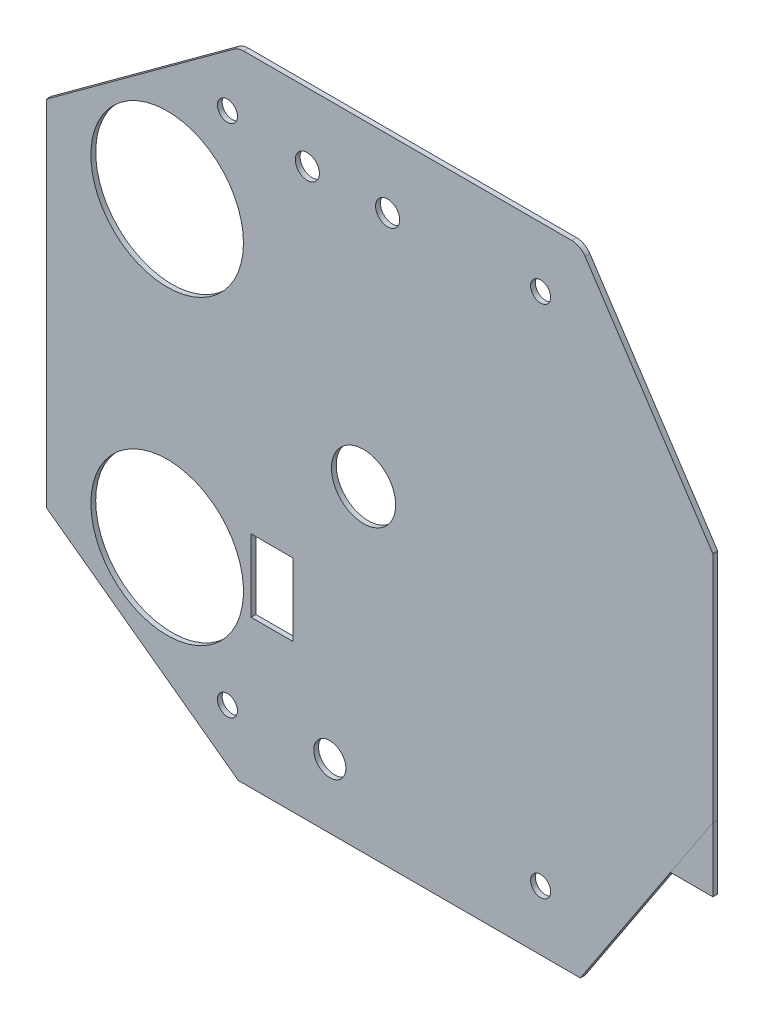
from build123d import *

# Parameters (mm, degrees)
ESQUISSE3_R      = 9.5
ESQUISSE3_R_2    = 4
ESQUISSE3_R_3    = 1.25
EXTRUSION1_DEPTH = 0.6
EXTRUSION2_DEPTH = 0.6
ESQUISSE5_R      = 2
ESQUISSE5_R_2    = 1.5
ESQUISSE5_W      = 5.2
ESQUISSE5_H      = 9
EXTRUSION3_DEPTH = 0.6


with BuildPart() as part:
    # Esquisse3 → Extrusion1 (new body)
    with BuildSketch(Plane.XY):
        with BuildLine():
            Line((23.383856403, 39.114616662), (0, 22.021380389))
            Line((0, 22.021380389), (0, -22.021380389))
            Line((0, -22.021380389), (23.91106778, -39.5))
            Line((23.91106778, -39.5), (66.5, -39.5))
            Line((66.5, -39.5), (83, -14.5))
            Line((83, -14.5), (83, 14.5))
            Line((83, 14.5), (67.092888285, 38.601684417))
            ThreePointArc((67.092888285, 38.601684417), (66.371464589, 39.261159963), (65.423669472, 39.5))
            Line((65.423669472, 39.5), (24.564116135, 39.5))
            ThreePointArc((24.564116135, 39.5), (23.943323627, 39.401214523), (23.383856403, 39.114616662))
        make_face()
        with Locations((15.050623147, 18.778285182)):
            Circle(ESQUISSE3_R, mode=Mode.SUBTRACT)
        with Locations((39.5, 0)):
            Circle(ESQUISSE3_R_2, mode=Mode.SUBTRACT)
        with Locations((22.550623147, 32.05)):
            Circle(ESQUISSE3_R_3, mode=Mode.SUBTRACT)
        with Locations((61.550623147, 32.05)):
            Circle(ESQUISSE3_R_3, mode=Mode.SUBTRACT)
        with Locations(Location((61.550623147, -32.05, 0), (0, 0, 180))):  # turned: the seam where the file's is
            Circle(ESQUISSE3_R_3, mode=Mode.SUBTRACT)
        with Locations(Location((22.550623147, -32.05, 0), (0, 0, 180))):  # turned: the seam where the file's is
            Circle(ESQUISSE3_R_3, mode=Mode.SUBTRACT)
        with Locations(Location((15.050623147, -18.778285182, 0), (0, 0, 180))):  # turned: the seam where the file's is
            Circle(ESQUISSE3_R, mode=Mode.SUBTRACT)
    extrude(amount=EXTRUSION1_DEPTH)

    # Esquisse5 → Extrusion3 (cut)
    with BuildSketch(Plane.XY.offset(0.6)):
        with Locations((35.300623147, -31.5)):
            Circle(ESQUISSE5_R)
        with Locations((32.5, 31)):
            Circle(ESQUISSE5_R_2)
        with Locations((42.5, 31)):
            Circle(ESQUISSE5_R_2)
        with Locations((28.1, -16.6)):
            Rectangle(ESQUISSE5_W, ESQUISSE5_H)
    extrude(amount=-EXTRUSION3_DEPTH, mode=Mode.SUBTRACT)


with BuildPart() as body_2:
    # Esquisse4 → Extrusion2 (new body)
    with BuildSketch(Plane.XY.offset(0.6)):
        Polygon((83, -14.5), (83, -22.5), (77.72, -22.5), align=None)
    extrude(amount=-EXTRUSION2_DEPTH)


solid = Compound([part.part, body_2.part])
